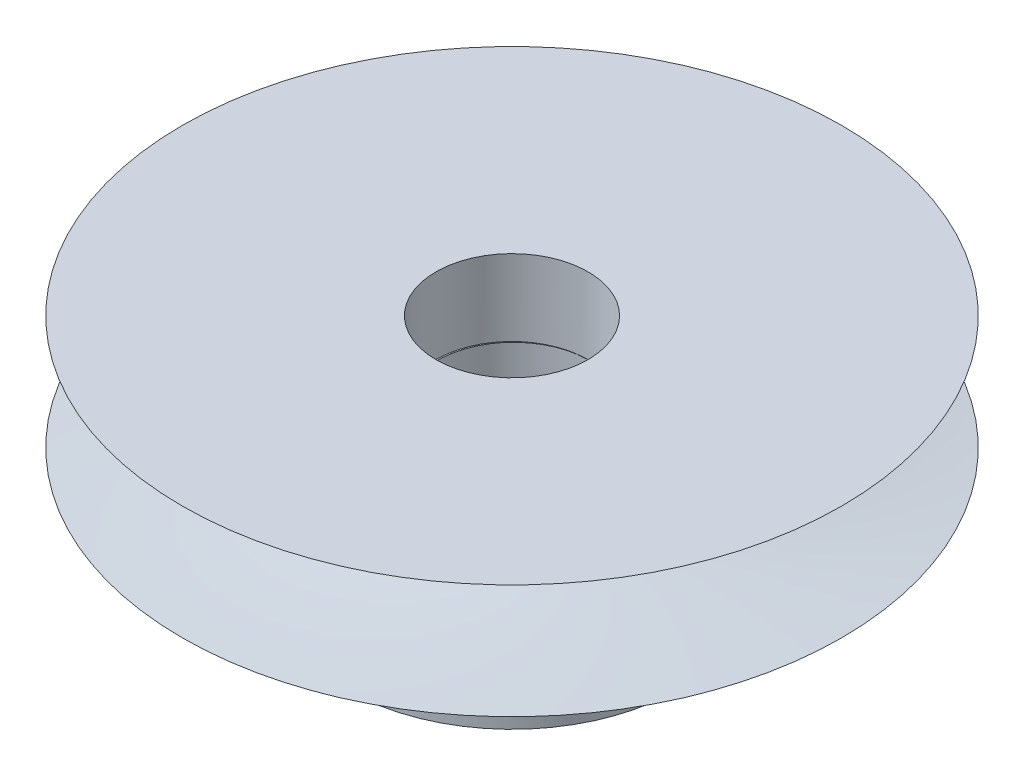
from build123d import *

# Parameters (mm, degrees)
SKETCH117_R           = 3
CUT_EXTRUDE4_DEPTH    = 3
SKETCH122_R           = 6.539767279
BOSS_EXTRUDE1_DEPTH   = 5
M2X0_4_TAPPED_HOLE1_D = 1.6
SKETCH125_R           = 3
CUT_EXTRUDE5_DEPTH    = 7


with BuildPart() as part:
    # Sketch9 → Revolve1 (revolve)
    with BuildSketch(Plane.XY):
        with BuildLine():
            Line((-4.703089141, -2.935363462), (8.296910859, -2.935363462))
            Line((8.296910859, -2.935363462), (8.296910859, 1.564636538))
            Line((8.296910859, 1.564636538), (-4.703089141, 1.564636538))
            add(Edge.make_bspline(
                [(-4.703089141, 1.564636538), (8.296910859, -1.435363462), (-4.703089141, -2.935363462)],
                knots=[0, 0, 0, 1, 1, 1], degree=2))
        make_face()
    revolve(axis=Axis((8.296910859, -2.935363462, 0), (0, 1, 0)))

    # Sketch117 → Cut-Extrude4 (cut)
    with BuildSketch(Plane(origin=(0, 1.564636538, 0), x_dir=(1, 0, 0), z_dir=(0, 1, 0))):
        with Locations((8.29691086, 0)):
            Circle(SKETCH117_R)
    extrude(amount=-CUT_EXTRUDE4_DEPTH, mode=Mode.SUBTRACT)

    # Sketch122 → Boss-Extrude1 (add)
    with BuildSketch(Plane(origin=(0, -2.935363462, 0), x_dir=(-1, 0, 0), z_dir=(0, -1, 0))):
        with Locations((-8.29691086, 0)):
            Circle(SKETCH122_R)
    extrude(amount=BOSS_EXTRUDE1_DEPTH)

    # M2x0.4 Tapped Hole1 (through all)
    with Locations(Plane(origin=(1.815385484, -5.431649491, -0.870852953), x_dir=(0.133162682, 0, -0.991094193), z_dir=(-0.991094193, 0, -0.133162682))):
        with Locations((0, 0)):
            Hole(M2X0_4_TAPPED_HOLE1_D / 2)

    # Sketch125 → Cut-Extrude5 (cut)
    with BuildSketch(Plane(origin=(0, -1.435363462, 0), x_dir=(1, 0, 0), z_dir=(0, 1, 0))):
        with Locations((8.350281981, 0)):
            Circle(SKETCH125_R)
    extrude(amount=-CUT_EXTRUDE5_DEPTH, mode=Mode.SUBTRACT)


solid = part.part
